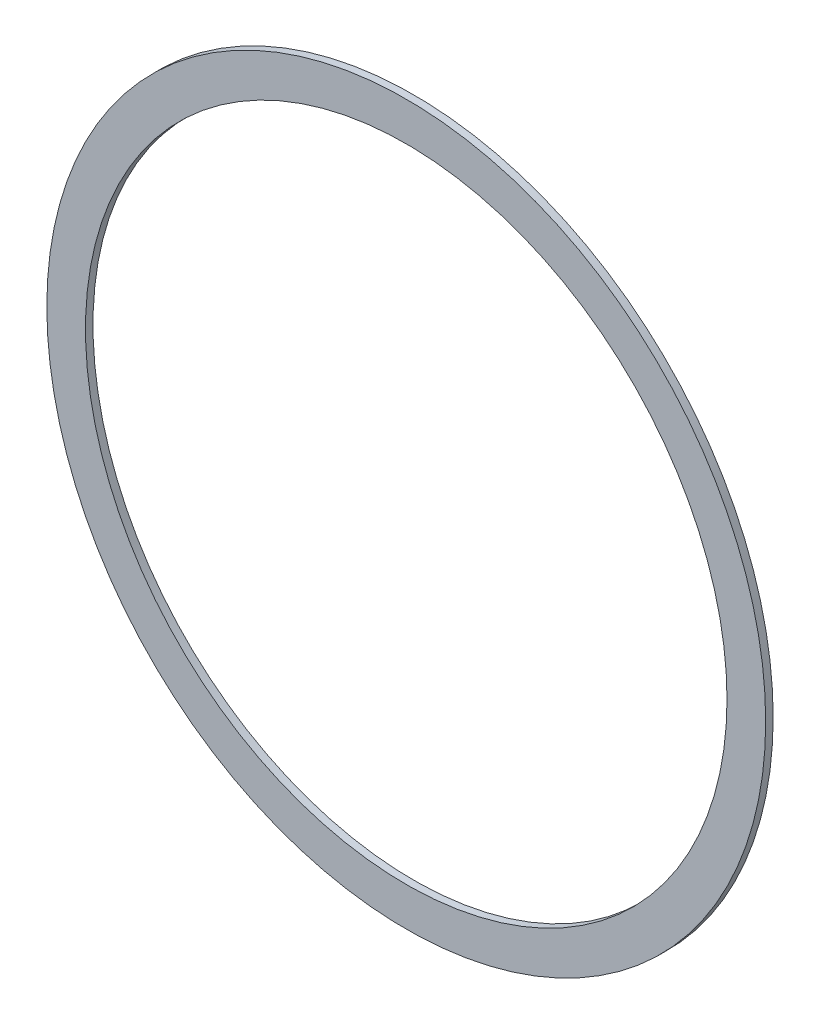
from build123d import *

# Parameters (mm, degrees)
SKETCH1_R           = 19.05
SKETCH1_R_2         = 17
BOSS_EXTRUDE1_DEPTH = 0.396875


with BuildPart() as part:
    # Sketch1 → Boss-Extrude1 (new body)
    with BuildSketch(Plane.XY):
        Circle(SKETCH1_R)
        Circle(SKETCH1_R_2, mode=Mode.SUBTRACT)
    extrude(amount=BOSS_EXTRUDE1_DEPTH)


solid = part.part
